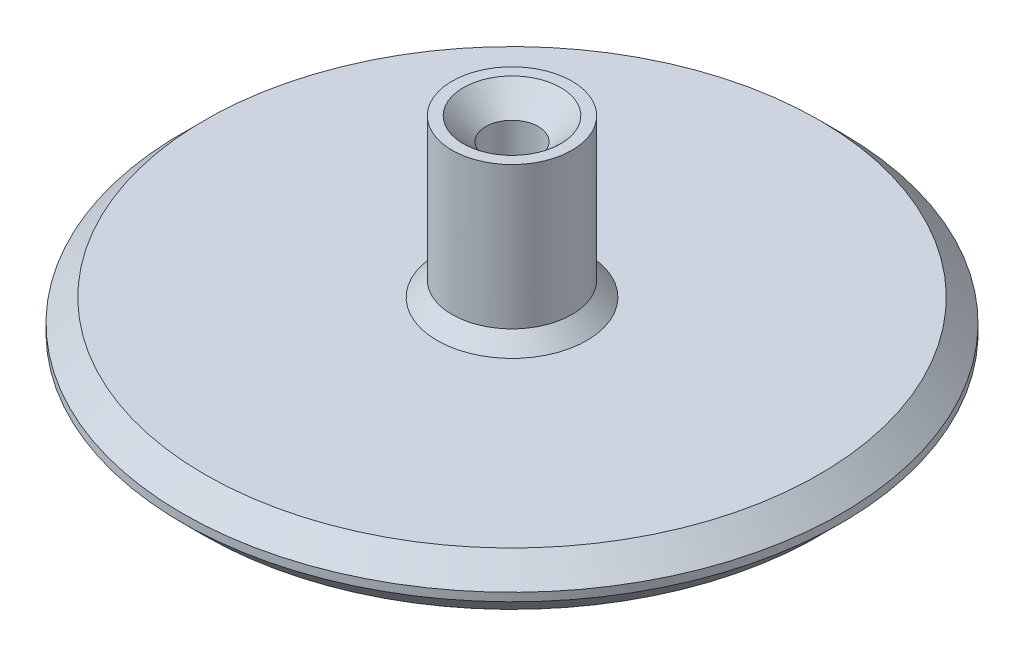
from build123d import *

# Parameters (mm, degrees)
SKETCH1_W     = 2.25
SKETCH1_H     = 10.5
SKETCH1_W_2   = 20
SKETCH1_H_2   = 1.5
CHAMFER1_SIZE = 1.5
CHAMFER2_SIZE = 1


with BuildPart() as part:
    # Sketch1 → Revolve1 (revolve)
    with BuildSketch(Plane.XY):
        Polygon((-20, 3.55), (-20, 2.05), (-1.75, 2.05), (-1.75, 3.55), (-4, 3.55), align=None)
        Polygon((-22, 0), (-20, 0), (-20, 1.5), (-20, 2.05), (-20, 3.55), (-22, 3.55), align=None)
        with Locations((-2.875, 8.8)):
            Rectangle(SKETCH1_W, SKETCH1_H)
        with Locations((-10, 0.75)):
            Rectangle(SKETCH1_W_2, SKETCH1_H_2)
    revolve(axis=Axis((0, 0, 0), (0, 1, 0)))

    # Chamfer1
    chamfer1_edges = [part.edges().sort_by_distance(p)[0] for p in [
        (22, 0, 0),
        (22, 3.55, 0),
        (1.75, 14.05, 0),
    ]]
    chamfer(chamfer1_edges, length=CHAMFER1_SIZE)

    # Chamfer2
    chamfer2_edges = [part.edges().sort_by_distance(p)[0] for p in [
        (4, 3.55, 0),
    ]]
    chamfer(chamfer2_edges, length=CHAMFER2_SIZE)


solid = part.part
